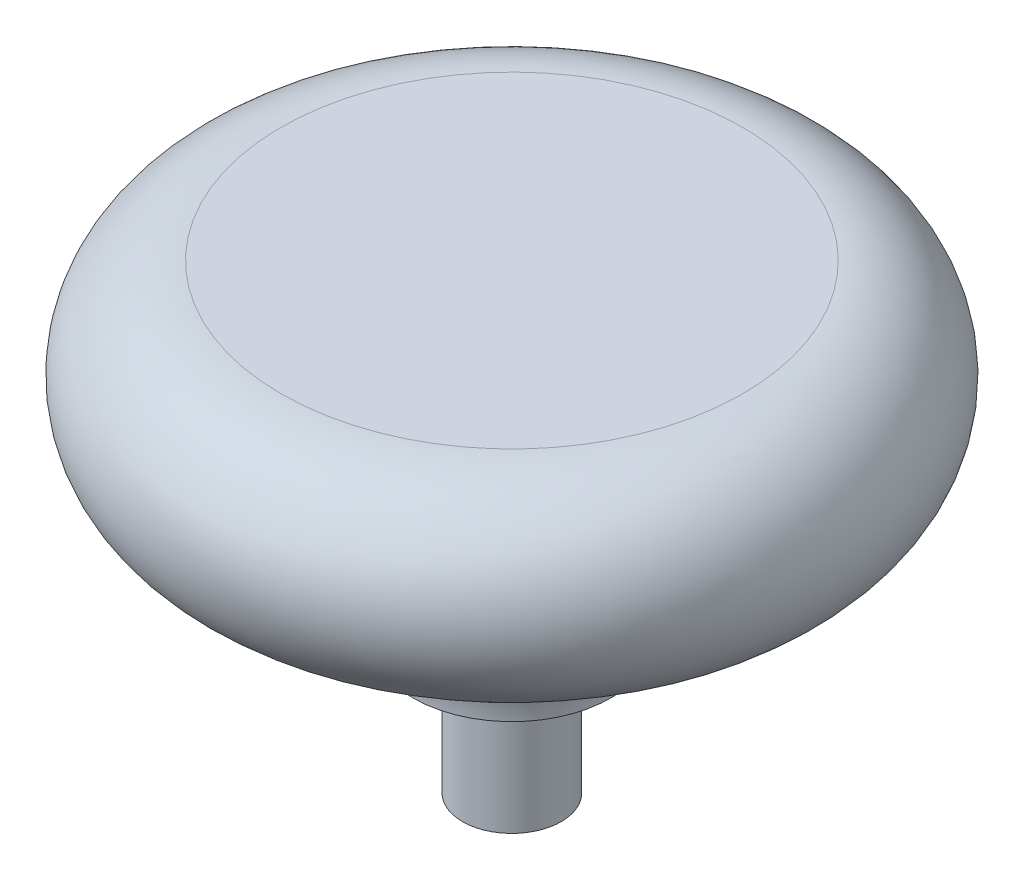
from build123d import *


with BuildPart() as part:
    # Sketch1 → Revolve1 (revolve)
    with BuildSketch(Plane.XY):
        with BuildLine():
            Line((11.12, 11.11), (0, 11.11))
            Line((0, 11.11), (0, -11.11))
            Line((0, -11.11), (2.38, -11.11))
            Line((2.38, -11.11), (2.38, -4.76))
            Line((2.38, -4.76), (4.765, -4.76))
            ThreePointArc((4.765, -4.76), (6.626639358, -0.268103248), (11.12, 1.59))
            ThreePointArc((11.12, 1.59), (15.88, 6.35), (11.12, 11.11))
        make_face()
    revolve(axis=Axis((0, 36.660350877, 0), (0, -1, 0)))


solid = part.part
